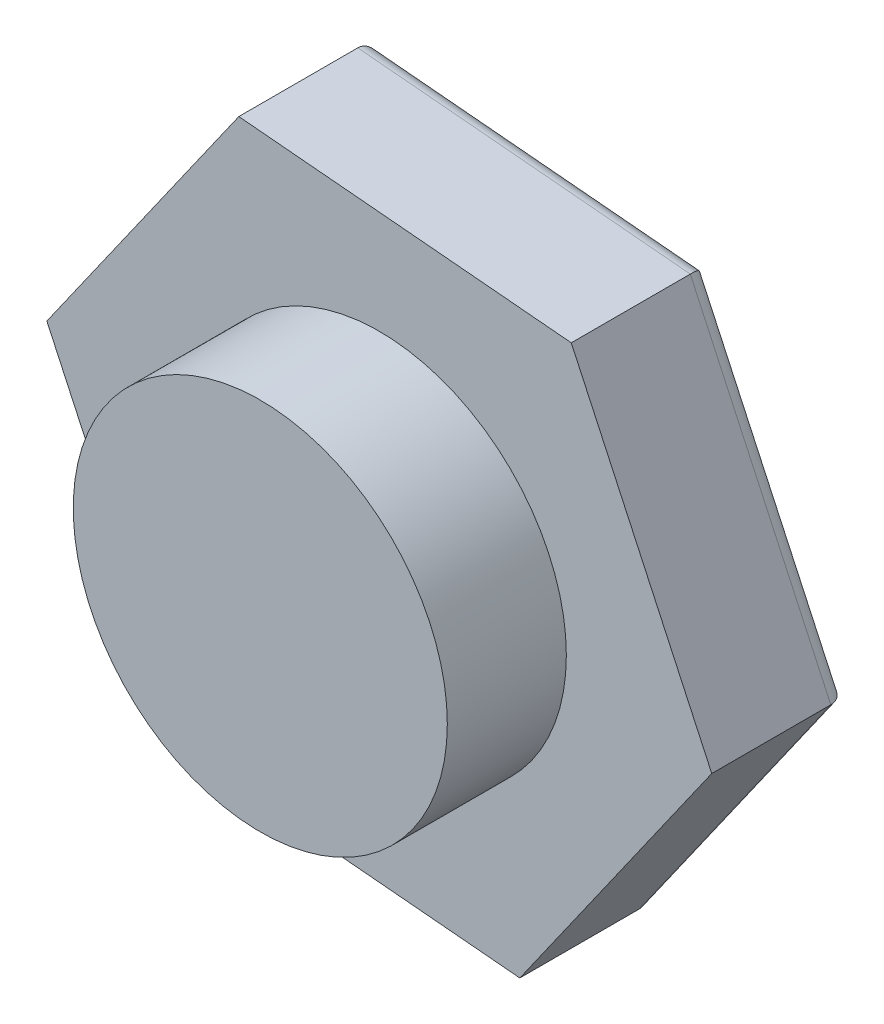
from build123d import *

# Parameters (mm, degrees)
SCHIZZO1_R                   = 11
ESTRUSIONE_ESTRUSIONE1_DEPTH = 7
ESTRUSIONE_ESTRUSIONE2_DEPTH = 8
RACCORDO1_R                  = 1


with BuildPart() as part:
    # Schizzo1 → Estrusione-Estrusione1 (new body)
    with BuildSketch(Plane.XY):
        Circle(SCHIZZO1_R)
    extrude(amount=ESTRUSIONE_ESTRUSIONE1_DEPTH)

    # Schizzo2 → Estrusione-Estrusione2 (add)
    with BuildSketch(Plane(origin=(0, 0, 0), x_dir=(-1, 0, 0), z_dir=(0, 0, -1))):
        Polygon((-19.551988484, -1.747306402), (-8.26278251, -17.806171922), (11.289205974, -16.058865521), (19.551988484, 1.747306402), (8.26278251, 17.806171922), (-11.289205974, 16.058865521), align=None)
    extrude(amount=ESTRUSIONE_ESTRUSIONE2_DEPTH)

    # Raccordo1
    raccordo1_edges = [part.edges().sort_by_distance(p)[0] for p in [
        (15.420597229, 7.155779559, -8),
        (13.907385497, -9.776739162, -8),
        (-1.513211732, -16.932518721, -8),
        (-15.420597229, -7.155779559, -8),
        (-13.907385497, 9.776739162, -8),
        (1.513211732, 16.932518721, -8),
    ]]
    fillet(raccordo1_edges, radius=RACCORDO1_R)


solid = part.part
